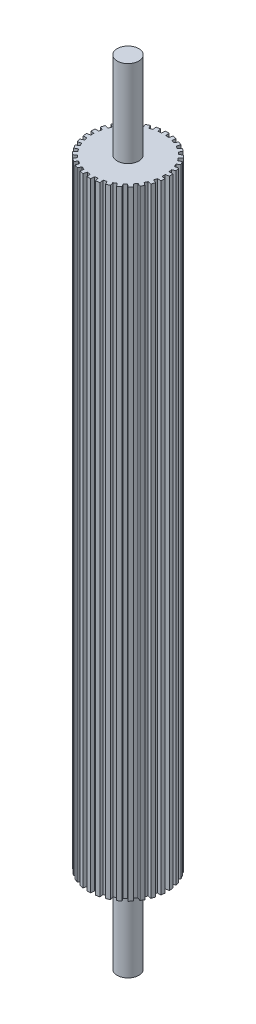
from build123d import *

# Parameters (mm, degrees)
BOSS_EXTRUDE1_DEPTH = 211.1375
SCALE2_SCALE_X      = 0.96
SCALE2_SCALE_Y      = 1
SCALE2_SCALE_Z      = 0.96
SKETCH3_R           = 3.68046
BOSS_EXTRUDE2_DEPTH = 29.55925
SKETCH4_R           = 3.68046
BOSS_EXTRUDE3_DEPTH = 29.55925


with BuildPart() as part:
    # Sketch2 → Boss-Extrude1 (new body)
    with BuildSketch(Plane(origin=(0, 0, 0), x_dir=(1, 0, 0), z_dir=(0, 1, 0))):
        with BuildLine():
            Line((-0.775316452, 12.67631194), (-0.670254455, 13.953911959))
            ThreePointArc((-0.670254455, 13.953911959), (0, 13.97), (0.670254455, 13.953911959))
            Line((0.670254455, 13.953911959), (0.775316452, 12.67631194))
            ThreePointArc((0.775316452, 12.67631194), (1.327511483, 12.630428071), (1.877179521, 12.560501465))
            Line((1.877179521, 12.560501465), (2.245573641, 13.788339241))
            ThreePointArc((2.245573641, 13.788339241), (2.904526321, 13.664721982), (3.556789216, 13.509631767))
            Line((3.556789216, 13.509631767), (3.393927376, 12.238106756))
            ThreePointArc((3.393927376, 12.238106756), (3.924515829, 12.078417757), (4.447633742, 11.895736803))
            Line((4.447633742, 11.895736803), (5.063259395, 13.020149934))
            ThreePointArc((5.063259395, 13.020149934), (5.682110904, 12.762230043), (6.287875221, 12.474915839))
            Line((6.287875221, 12.474915839), (5.864207388, 11.265037581))
            ThreePointArc((5.864207388, 11.265037581), (6.35, 10.998522628), (6.823705026, 10.711071362))
            Line((6.823705026, 10.711071362), (7.659656416, 11.682917597))
            ThreePointArc((7.659656416, 11.682917597), (8.211359975, 11.301967411), (8.744150906, 10.894986229))
            Line((8.744150906, 10.894986229), (8.078193398, 9.799632209))
            ThreePointArc((8.078193398, 9.799632209), (8.497958701, 9.437939284), (8.901547657, 9.058280704))
            Line((8.901547657, 9.058280704), (9.921289697, 9.835085701))
            ThreePointArc((9.921289697, 9.835085701), (10.381733212, 9.347754571), (10.818265238, 8.83889344))
            Line((10.818265238, 8.83889344), (9.939123592, 7.905935885))
            ThreePointArc((9.939123592, 7.905935885), (10.274515829, 7.464872704), (10.59034994, 7.009599713))
            Line((10.59034994, 7.009599713), (11.749315011, 7.557413365))
            ThreePointArc((11.749315011, 7.557413365), (12.098374891, 6.985), (12.419569467, 6.396498594))
            Line((12.419569467, 6.396498594), (11.365666392, 5.666712226))
            ThreePointArc((11.365666392, 5.666712226), (11.602027312, 5.165555367), (11.816303113, 4.654565579))
            Line((11.816303113, 4.654565579), (13.063838879, 4.949445801))
            ThreePointArc((13.063838879, 4.949445801), (13.286259533, 4.316967411), (13.478078914, 3.674546066))
            Line((13.478078914, 3.674546066), (12.295475033, 3.179826051))
            ThreePointArc((12.295475033, 3.179826051), (12.422474529, 2.640478473), (12.52582714, 2.096104594))
            Line((12.52582714, 2.096104594), (13.807410301, 2.125163705))
            ThreePointArc((13.807410301, 2.125163705), (13.893470878, 1.460262632), (13.947531638, 0.791998242))
            Line((13.947531638, 0.791998242), (12.687912414, 0.55396622))
            ThreePointArc((12.687912414, 0.55396622), (12.7, 0), (12.687912414, -0.55396622))
            Line((12.687912414, -0.55396622), (13.947531638, -0.791998242))
            ThreePointArc((13.947531638, -0.791998242), (13.893470878, -1.460262632), (13.807410301, -2.125163705))
            Line((13.807410301, -2.125163705), (12.52582714, -2.096104594))
            ThreePointArc((12.52582714, -2.096104594), (12.422474529, -2.640478473), (12.295475033, -3.179826051))
            Line((12.295475033, -3.179826051), (13.478078914, -3.674546066))
            ThreePointArc((13.478078914, -3.674546066), (13.286259533, -4.316967411), (13.063838879, -4.949445801))
            Line((13.063838879, -4.949445801), (11.816303113, -4.654565579))
            ThreePointArc((11.816303113, -4.654565579), (11.602027312, -5.165555367), (11.365666392, -5.666712226))
            Line((11.365666392, -5.666712226), (12.419569467, -6.396498594))
            ThreePointArc((12.419569467, -6.396498594), (12.098374891, -6.985), (11.749315011, -7.557413365))
            Line((11.749315011, -7.557413365), (10.59034994, -7.009599713))
            ThreePointArc((10.59034994, -7.009599713), (10.274515829, -7.464872704), (9.939123592, -7.905935885))
            Line((9.939123592, -7.905935885), (10.818265238, -8.83889344))
            ThreePointArc((10.818265238, -8.83889344), (10.381733212, -9.347754571), (9.921289697, -9.835085701))
            Line((9.921289697, -9.835085701), (8.901547657, -9.058280704))
            ThreePointArc((8.901547657, -9.058280704), (8.497958701, -9.437939284), (8.078193398, -9.799632209))
            Line((8.078193398, -9.799632209), (8.744150906, -10.894986229))
            ThreePointArc((8.744150906, -10.894986229), (8.211359975, -11.301967411), (7.659656416, -11.682917597))
            Line((7.659656416, -11.682917597), (6.823705026, -10.711071362))
            ThreePointArc((6.823705026, -10.711071362), (6.35, -10.998522628), (5.864207388, -11.265037581))
            Line((5.864207388, -11.265037581), (6.287875221, -12.474915839))
            ThreePointArc((6.287875221, -12.474915839), (5.682110904, -12.762230043), (5.063259395, -13.020149934))
            Line((5.063259395, -13.020149934), (4.447633742, -11.895736803))
            ThreePointArc((4.447633742, -11.895736803), (3.924515829, -12.078417757), (3.393927376, -12.238106756))
            Line((3.393927376, -12.238106756), (3.556789216, -13.509631767))
            ThreePointArc((3.556789216, -13.509631767), (2.904526321, -13.664721982), (2.245573641, -13.788339241))
            Line((2.245573641, -13.788339241), (1.877179521, -12.560501465))
            ThreePointArc((1.877179521, -12.560501465), (1.327511483, -12.630428071), (0.775316452, -12.67631194))
            Line((0.775316452, -12.67631194), (0.670254455, -13.953911959))
            ThreePointArc((0.670254455, -13.953911959), (0, -13.97), (-0.670254455, -13.953911959))
            Line((-0.670254455, -13.953911959), (-0.775316452, -12.67631194))
            ThreePointArc((-0.775316452, -12.67631194), (-1.327511483, -12.630428071), (-1.877179521, -12.560501465))
            Line((-1.877179521, -12.560501465), (-2.245573641, -13.788339241))
            ThreePointArc((-2.245573641, -13.788339241), (-2.904526321, -13.664721982), (-3.556789216, -13.509631767))
            Line((-3.556789216, -13.509631767), (-3.393927376, -12.238106756))
            ThreePointArc((-3.393927376, -12.238106756), (-3.924515829, -12.078417757), (-4.447633742, -11.895736803))
            Line((-4.447633742, -11.895736803), (-5.063259395, -13.020149934))
            ThreePointArc((-5.063259395, -13.020149934), (-5.682110904, -12.762230043), (-6.287875221, -12.474915839))
            Line((-6.287875221, -12.474915839), (-5.864207388, -11.265037581))
            ThreePointArc((-5.864207388, -11.265037581), (-6.35, -10.998522628), (-6.823705026, -10.711071362))
            Line((-6.823705026, -10.711071362), (-7.659656416, -11.682917597))
            ThreePointArc((-7.659656416, -11.682917597), (-8.211359975, -11.301967411), (-8.744150906, -10.894986229))
            Line((-8.744150906, -10.894986229), (-8.078193398, -9.799632209))
            ThreePointArc((-8.078193398, -9.799632209), (-8.497958701, -9.437939284), (-8.901547657, -9.058280704))
            Line((-8.901547657, -9.058280704), (-9.921289697, -9.835085701))
            ThreePointArc((-9.921289697, -9.835085701), (-10.381733212, -9.347754571), (-10.818265238, -8.83889344))
            Line((-10.818265238, -8.83889344), (-9.939123592, -7.905935885))
            ThreePointArc((-9.939123592, -7.905935885), (-10.274515829, -7.464872704), (-10.59034994, -7.009599713))
            Line((-10.59034994, -7.009599713), (-11.749315011, -7.557413365))
            ThreePointArc((-11.749315011, -7.557413365), (-12.098374891, -6.985), (-12.419569467, -6.396498594))
            Line((-12.419569467, -6.396498594), (-11.365666392, -5.666712226))
            ThreePointArc((-11.365666392, -5.666712226), (-11.602027312, -5.165555367), (-11.816303113, -4.654565579))
            Line((-11.816303113, -4.654565579), (-13.063838879, -4.949445801))
            ThreePointArc((-13.063838879, -4.949445801), (-13.286259533, -4.316967411), (-13.478078914, -3.674546066))
            Line((-13.478078914, -3.674546066), (-12.295475033, -3.179826051))
            ThreePointArc((-12.295475033, -3.179826051), (-12.422474529, -2.640478473), (-12.52582714, -2.096104594))
            Line((-12.52582714, -2.096104594), (-13.807410301, -2.125163705))
            ThreePointArc((-13.807410301, -2.125163705), (-13.893470878, -1.460262632), (-13.947531638, -0.791998242))
            Line((-13.947531638, -0.791998242), (-12.687912414, -0.55396622))
            ThreePointArc((-12.687912414, -0.55396622), (-12.7, 0), (-12.687912414, 0.55396622))
            Line((-12.687912414, 0.55396622), (-13.947531638, 0.791998242))
            ThreePointArc((-13.947531638, 0.791998242), (-13.893470878, 1.460262632), (-13.807410301, 2.125163705))
            Line((-13.807410301, 2.125163705), (-12.52582714, 2.096104594))
            ThreePointArc((-12.52582714, 2.096104594), (-12.422474529, 2.640478473), (-12.295475033, 3.179826051))
            Line((-12.295475033, 3.179826051), (-13.478078914, 3.674546066))
            ThreePointArc((-13.478078914, 3.674546066), (-13.286259533, 4.316967411), (-13.063838879, 4.949445801))
            Line((-13.063838879, 4.949445801), (-11.816303113, 4.654565579))
            ThreePointArc((-11.816303113, 4.654565579), (-11.602027312, 5.165555367), (-11.365666392, 5.666712226))
            Line((-11.365666392, 5.666712226), (-12.419569467, 6.396498594))
            ThreePointArc((-12.419569467, 6.396498594), (-12.098374891, 6.985), (-11.749315011, 7.557413365))
            Line((-11.749315011, 7.557413365), (-10.59034994, 7.009599713))
            ThreePointArc((-10.59034994, 7.009599713), (-10.274515829, 7.464872704), (-9.939123592, 7.905935885))
            Line((-9.939123592, 7.905935885), (-10.818265238, 8.83889344))
            ThreePointArc((-10.818265238, 8.83889344), (-10.381733212, 9.347754571), (-9.921289697, 9.835085701))
            Line((-9.921289697, 9.835085701), (-8.901547657, 9.058280704))
            ThreePointArc((-8.901547657, 9.058280704), (-8.497958701, 9.437939284), (-8.078193398, 9.799632209))
            Line((-8.078193398, 9.799632209), (-8.744150906, 10.894986229))
            ThreePointArc((-8.744150906, 10.894986229), (-8.211359975, 11.301967411), (-7.659656416, 11.682917597))
            Line((-7.659656416, 11.682917597), (-6.823705026, 10.711071362))
            ThreePointArc((-6.823705026, 10.711071362), (-6.35, 10.998522628), (-5.864207388, 11.265037581))
            Line((-5.864207388, 11.265037581), (-6.287875221, 12.474915839))
            ThreePointArc((-6.287875221, 12.474915839), (-5.682110904, 12.762230043), (-5.063259395, 13.020149934))
            Line((-5.063259395, 13.020149934), (-4.447633742, 11.895736803))
            ThreePointArc((-4.447633742, 11.895736803), (-3.924515829, 12.078417757), (-3.393927376, 12.238106756))
            Line((-3.393927376, 12.238106756), (-3.556789216, 13.509631767))
            ThreePointArc((-3.556789216, 13.509631767), (-2.904526321, 13.664721982), (-2.245573641, 13.788339241))
            Line((-2.245573641, 13.788339241), (-1.877179521, 12.560501465))
            ThreePointArc((-1.877179521, 12.560501465), (-1.327511483, 12.630428071), (-0.775316452, 12.67631194))
        make_face()
    extrude(amount=BOSS_EXTRUDE1_DEPTH)


with BuildPart() as part_1:
    # Scale2: scaled about (0, 105.56875, 0)
    add(part.part.scale((SCALE2_SCALE_X, SCALE2_SCALE_Y, SCALE2_SCALE_Z), about=(0, 105.56875, 0)))

    # Sketch3 → Boss-Extrude2 (add)
    with BuildSketch(Plane(origin=(0, 211.1375, 0), x_dir=(1, 0, 0), z_dir=(0, 1, 0))):
        Circle(SKETCH3_R)
    extrude(amount=BOSS_EXTRUDE2_DEPTH)

    # Sketch4 → Boss-Extrude3 (add)
    with BuildSketch(Plane(origin=(0, 0, 0), x_dir=(-1, 0, 0), z_dir=(0, -1, 0))):
        Circle(SKETCH4_R)
    extrude(amount=BOSS_EXTRUDE3_DEPTH)


solid = part_1.part
